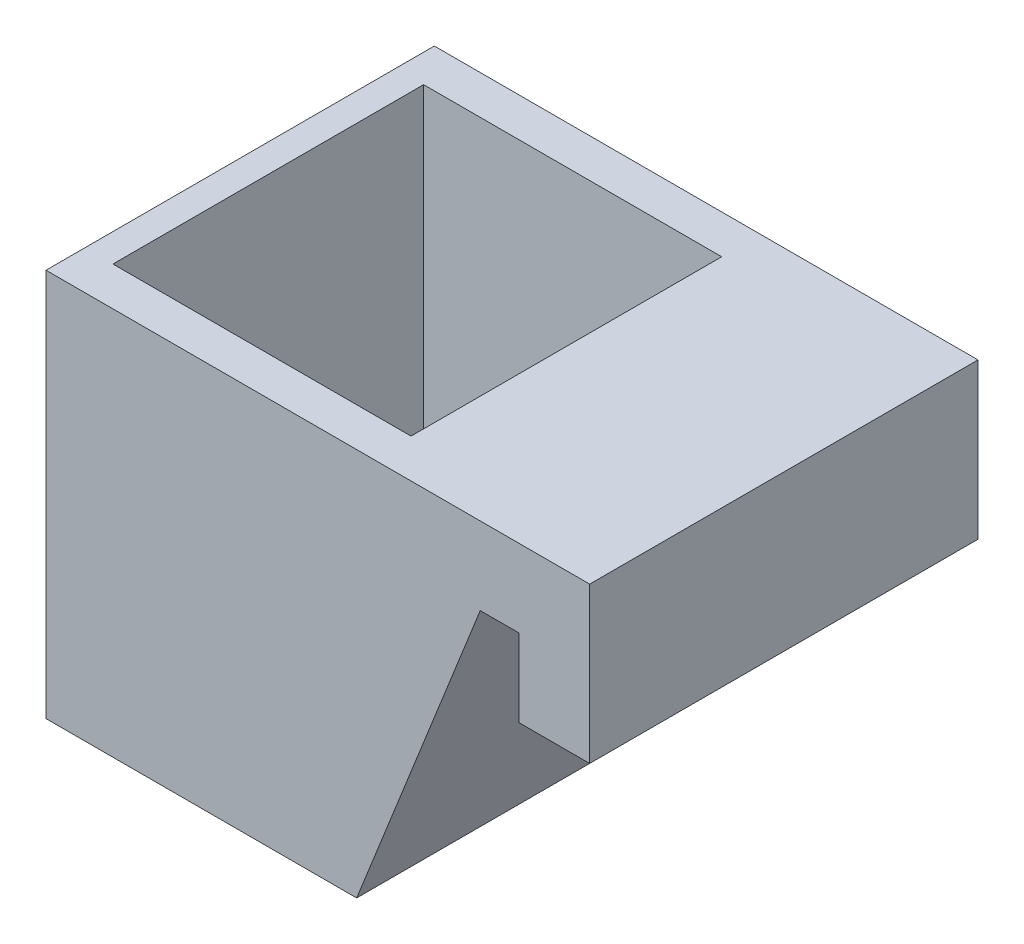
from build123d import *

# Parameters (mm, degrees)
BOSS_EXTRUDE1_DEPTH = 50
SKETCH2_W           = 38.381895626
SKETCH2_H           = 40
CUT_EXTRUDE2_DEPTH  = 41
SKETCH4_W           = 6.790896345
SKETCH4_H           = 3.798015254
CUT_EXTRUDE3_DEPTH  = 5


with BuildPart() as part:
    # Sketch1 → Boss-Extrude1 (new body)
    with BuildSketch(Plane.XY):
        Polygon((-55.909090909, 31.818181818), (-55.909090909, -18.181818182), (-15.909090909, -18.181818182), (0, 21.818181818), (5, 21.818181818), (5, 11.818181818), (14.090909091, 11.818181818), (14.090909091, 31.818181818), align=None)
    extrude(amount=BOSS_EXTRUDE1_DEPTH)

    # Sketch2 → Cut-Extrude2 (cut)
    with BuildSketch(Plane(origin=(0, 31.818181818, 0), x_dir=(1, 0, 0), z_dir=(0, 1, 0))):
        with Locations((-33.100038722, -25)):
            Rectangle(SKETCH2_W, SKETCH2_H)
    extrude(amount=-CUT_EXTRUDE2_DEPTH, mode=Mode.SUBTRACT)

    # Sketch4 → Cut-Extrude3 (cut)
    with BuildSketch(Plane.XY.offset(5)):
        with Locations((-34.961451434, -5.442472673)):
            Rectangle(SKETCH4_W, SKETCH4_H)
    extrude(amount=-CUT_EXTRUDE3_DEPTH, mode=Mode.SUBTRACT)


solid = part.part
